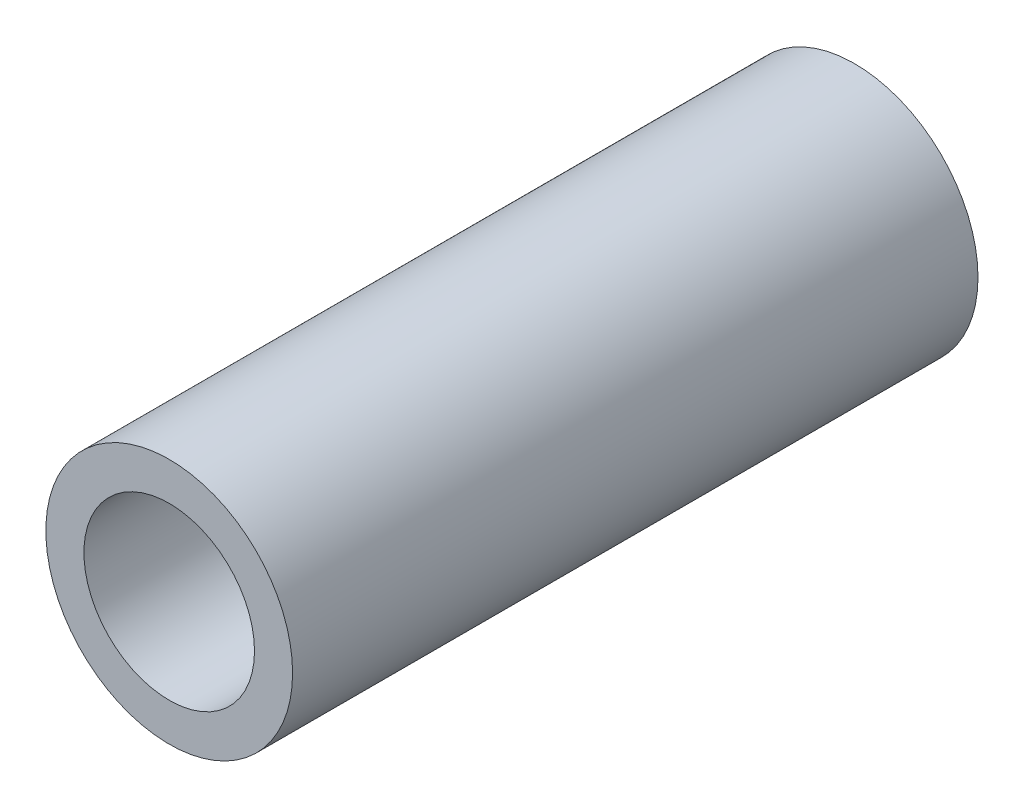
from build123d import *

# Parameters (mm, degrees)
SKETCH_1_R          = 6.479851608
EXTRUDE_1_DEPTH     = 36
CUT_EXTRUDE_1_REACH = 38
SKETCH_2_R          = 4.479851608


with BuildPart() as part:
    # 草图1 → 凸台-拉伸1 (new body)
    with BuildSketch(Plane.XY):
        with Locations((-11.218780453, 18.059525174)):
            Circle(SKETCH_1_R)
    extrude(amount=EXTRUDE_1_DEPTH)

    # 草图2 → 切除-拉伸1 (cut, up to next)
    with BuildSketch(Plane.XY.offset(36), mode=Mode.PRIVATE) as cut_extrude_1_sk1:
        with Locations((-11.218780453, 18.059525174)):
            Circle(SKETCH_2_R)
    cut_extrude_1_tool1 = extrude(cut_extrude_1_sk1.sketch, amount=-CUT_EXTRUDE_1_REACH, mode=Mode.PRIVATE) & part.part
    add(cut_extrude_1_tool1.solids().sort_by_distance((-11.21878, 18.059525, 36))[0], mode=Mode.SUBTRACT)


solid = part.part
